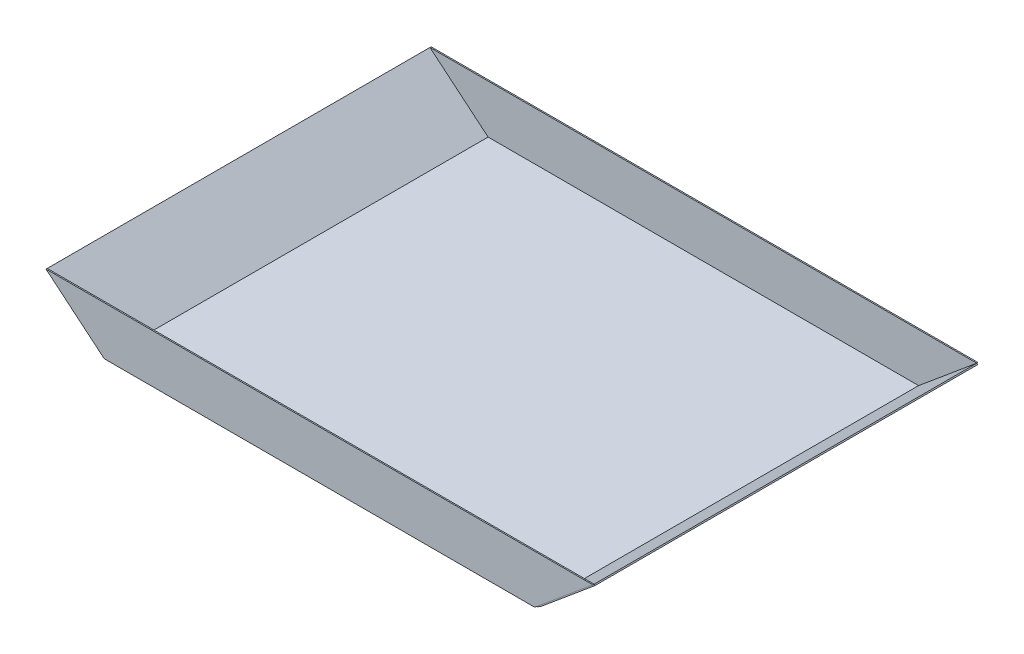
from build123d import *

# Parameters (mm, degrees)
EXTRUDE_THIN1_DEPTH = 501.65
FILLET1_R           = 25.4
BOSS_EXTRUDE1_DEPTH = 1.5875
BOSS_EXTRUDE2_DEPTH = 1.5875


with BuildPart() as part:
    # Sketch1 → Extrude-Thin1 (new body)
    with BuildSketch(Plane.XY):
        Polygon((-76.290213318, 63.585170817), (0, 0), (564.261, 0), (640.551213318, 63.585170817), (641.56760032, 62.365698098), (564.835823672, -1.5875), (-0.574823672, -1.5875), (-77.30660032, 62.365698098), align=None)
    extrude(amount=EXTRUDE_THIN1_DEPTH)

    # Fillet1
    fillet1_edges = [part.edges().sort_by_distance(p)[0] for p in [
        (564.835823672, -1.5875, 250.825),
        (-0.574823672, -1.5875, 250.825),
    ]]
    fillet(fillet1_edges, radius=FILLET1_R)


with BuildPart() as body_2:
    # Sketch2 → Boss-Extrude1 (new body)
    with BuildSketch(Plane.XY.offset(501.65)):
        Polygon((-76.290213318, 63.585170817), (640.551213318, 63.585170817), (564.261, 0), (0, 0), align=None)
    extrude(amount=BOSS_EXTRUDE1_DEPTH)


with BuildPart() as body_3:
    # Sketch3 → Boss-Extrude2 (new body)
    with BuildSketch(Plane(origin=(0, 0, 0), x_dir=(-1, 0, 0), z_dir=(0, 0, -1))):
        Polygon((-640.551213318, 63.585170817), (76.290213318, 63.585170817), (0, 0), (-564.261, 0), align=None)
    extrude(amount=BOSS_EXTRUDE2_DEPTH)


solid = Compound([part.part, body_2.part, body_3.part])
